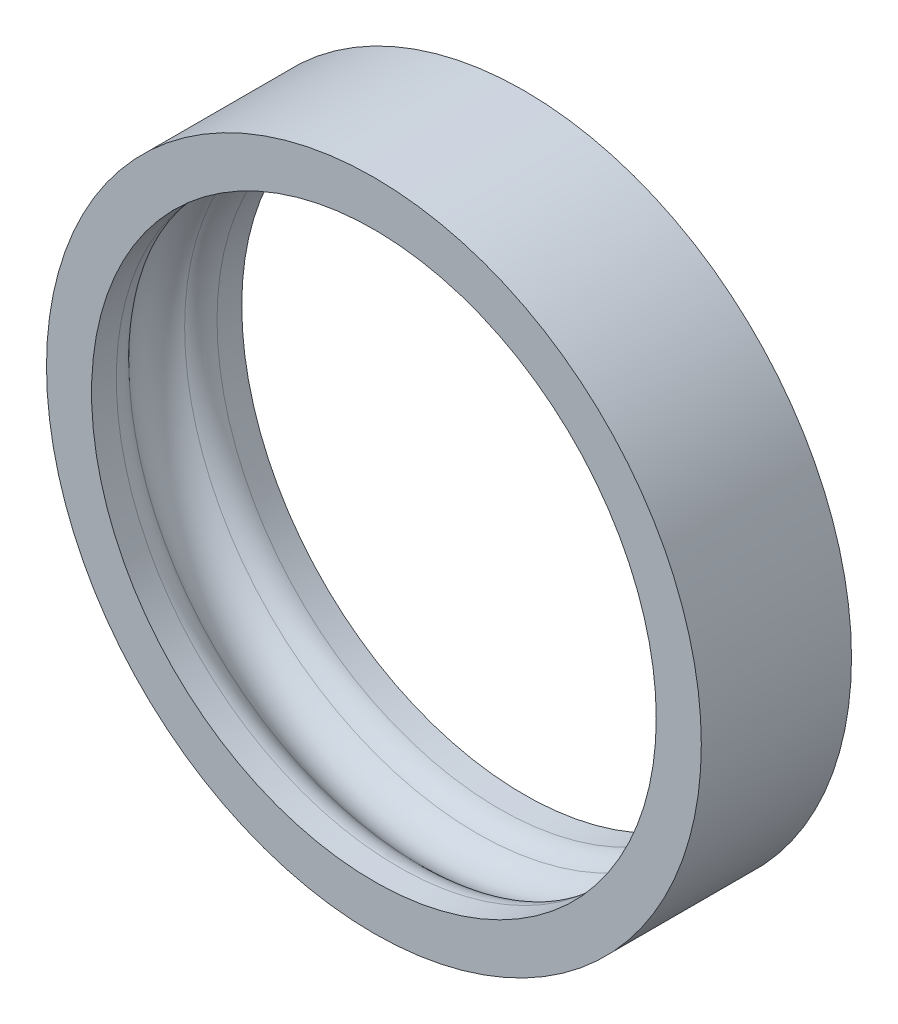
from build123d import *

# Parameters (mm, degrees)
SKETCH_1_R      = 10.9
SKETCH_1_R_2    = 9.4
EXTRUDE_1_DEPTH = 2.5
SKETCH_3_R      = 1.25
FILLET_1_R      = 1


with BuildPart() as part:
    # 草图1 → 凸台-拉伸1 (new body, symmetric)
    with BuildSketch(Plane.XY):
        Circle(SKETCH_1_R)
        Circle(SKETCH_1_R_2, mode=Mode.SUBTRACT)
    extrude(amount=EXTRUDE_1_DEPTH, both=True)

    # 草图3 → 切除-旋转1 (revolve, cut)
    with BuildSketch(Plane(origin=(0, 0, 0), x_dir=(1, 0, 0), z_dir=(0, 1, 0))):
        with Locations((-8.9, 0)):
            Circle(SKETCH_3_R)
    revolve(axis=Axis((0, 0, 2.5), (0, 0, -1)), mode=Mode.SUBTRACT)

    # 圆角1
    fillet_1_edges = [part.edges().sort_by_distance(p)[0] for p in [
        (0, 9.4, 1.145643924),
        (0, -9.4, -1.145643924),
    ]]
    fillet(fillet_1_edges, radius=FILLET_1_R)


solid = part.part
